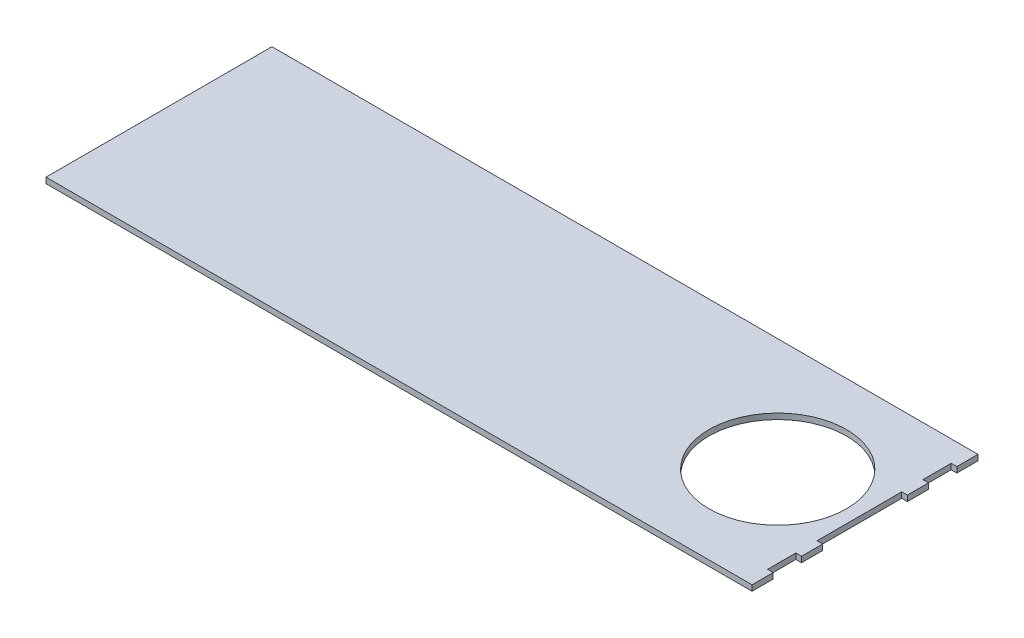
from build123d import *

# Parameters (mm, degrees)
SKETCH1_W           = 635
SKETCH1_H           = 203.2
BOSS_EXTRUDE1_DEPTH = 5.08
SKETCH2_W           = 5.08
SKETCH2_H           = 25.4
SKETCH2_H_2         = 76.2
CUT_EXTRUDE1_DEPTH  = 5.08
SKETCH3_R           = 61.809841791
CUT_EXTRUDE2_DEPTH  = 5.08


with BuildPart() as part:
    # Sketch1 → Boss-Extrude1 (new body)
    with BuildSketch(Plane(origin=(0, 0, 0), x_dir=(1, 0, 0), z_dir=(0, 1, 0))):
        Rectangle(SKETCH1_W, SKETCH1_H)
    extrude(amount=BOSS_EXTRUDE1_DEPTH)

    # Sketch2 → Cut-Extrude1 (cut)
    with BuildSketch(Plane(origin=(0, 5.08, 0), x_dir=(1, 0, 0), z_dir=(0, 1, 0))):
        with Locations((314.96, 69.85)):
            Rectangle(SKETCH2_W, SKETCH2_H)
        with Locations((314.96, -69.85)):
            Rectangle(SKETCH2_W, SKETCH2_H)
        with Locations((314.96, 0)):
            Rectangle(SKETCH2_W, SKETCH2_H_2)
    extrude(amount=-CUT_EXTRUDE1_DEPTH, mode=Mode.SUBTRACT)

    # Sketch3 → Cut-Extrude2 (cut)
    with BuildSketch(Plane(origin=(0, 5.08, 0), x_dir=(1, 0, 0), z_dir=(0, 1, 0))):
        with Locations((238.966470336, 0)):
            Circle(SKETCH3_R)
    extrude(amount=-CUT_EXTRUDE2_DEPTH, mode=Mode.SUBTRACT)


solid = part.part
